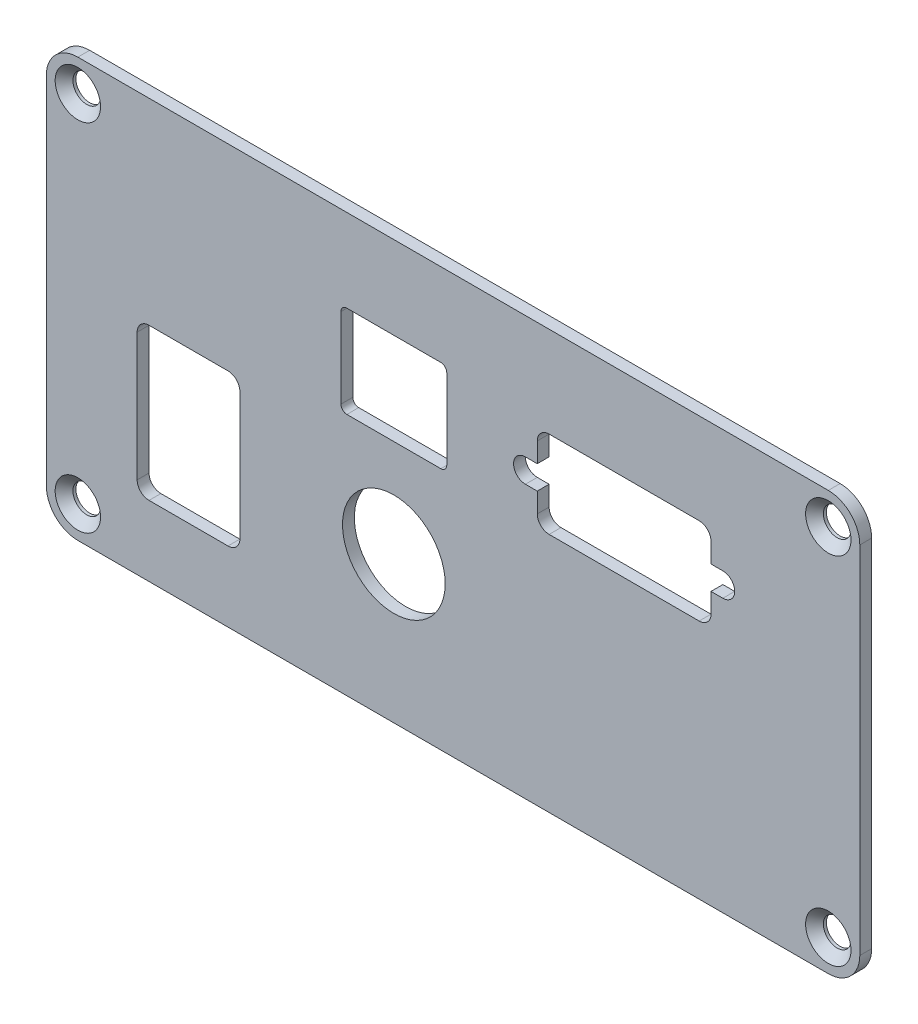
from build123d import *

# Parameters (mm, degrees)
ESQUISSE1_W                                 = 103
ESQUISSE1_H                                 = 53
BOSS_EXTRU_1_DEPTH                          = 1.5
FRAISAGE_POUR_VIS_T_TE_FRAIS_E_M31_AT_COUNT = 2
FRAISAGE_POUR_VIS_T_TE_FRAIS_E_M31_AT_PITCH = 95.02
FRAISAGE_POUR_VIS_T_TE_FRAIS_E_M31_2_COUNT  = 2
FRAISAGE_POUR_VIS_T_TE_FRAIS_E_M31_2_PITCH  = 105.137055314
FRAISAGE_POUR_VIS_T_TE_FRAIS_E_M31_3_COUNT  = 2
FRAISAGE_POUR_VIS_T_TE_FRAIS_E_M31_3_PITCH  = 45
CONG_1_R                                    = 3.99
ESQUISSE5_R                                 = 6.5
ENL_V_MAT_EXTRU_1_DEPTH                     = 2.5


with BuildPart() as part:
    # Esquisse1 → Boss.-Extru.1 (new body)
    with BuildSketch(Plane(origin=(0, 0, -0.75), x_dir=(-1, 0, 0), z_dir=(0, 0, -1))):
        Rectangle(ESQUISSE1_W, ESQUISSE1_H)
    extrude(amount=-BOSS_EXTRU_1_DEPTH)

    # Esquisse2 → Fraisage pour vis à tête fraisée M31 (revolve, cut)
    with BuildSketch(Plane(origin=(-47.51, 22.5, 0.75), x_dir=(0, -1, 0), z_dir=(1, 0, 0))):
        Polygon((0, 0), (0, 1.5), (1.75, 1.5), (1.75, 1.125), (2.875, 0), align=None)
    fraisage_pour_vis_t_te_frais_e_m31 = revolve(axis=Axis((-47.51, 22.5, 7.1), (0, 0, -1)), mode=Mode.SUBTRACT)

    # Fraisage pour vis à tête fraisée M31 at: Fraisage pour vis à tête fraisée M31 ×2
    with Locations(*[(i * FRAISAGE_POUR_VIS_T_TE_FRAIS_E_M31_AT_PITCH, 0, 0) for i in range(1, FRAISAGE_POUR_VIS_T_TE_FRAIS_E_M31_AT_COUNT)]):
        add(fraisage_pour_vis_t_te_frais_e_m31, mode=Mode.SUBTRACT)

    # Fraisage pour vis _ t_te frais_e M31 2: Fraisage pour vis à tête fraisée M31 ×2
    with Locations(*[Vector(0.903772697, -0.428012748, 0) * (i * FRAISAGE_POUR_VIS_T_TE_FRAIS_E_M31_2_PITCH) for i in range(1, FRAISAGE_POUR_VIS_T_TE_FRAIS_E_M31_2_COUNT)]):
        add(fraisage_pour_vis_t_te_frais_e_m31, mode=Mode.SUBTRACT)

    # Fraisage pour vis _ t_te frais_e M31 3: Fraisage pour vis à tête fraisée M31 ×2
    with Locations(*[(0, -i * FRAISAGE_POUR_VIS_T_TE_FRAIS_E_M31_3_PITCH, 0) for i in range(1, FRAISAGE_POUR_VIS_T_TE_FRAIS_E_M31_3_COUNT)]):
        add(fraisage_pour_vis_t_te_frais_e_m31, mode=Mode.SUBTRACT)

    # Congé1
    cong_1_edges = [part.edges().sort_by_distance(p)[0] for p in [
        (51.5, 26.5, 0),
        (-51.5, 26.5, 0),
        (-51.5, -26.5, 0),
        (51.5, -26.5, 0),
    ]]
    fillet(cong_1_edges, radius=CONG_1_R)

    # Esquisse5 → Enlèv. mat.-Extru.1 (cut, through all)
    with BuildSketch(Plane.XY.offset(0.75)):
        with Locations((-7.5, -8)):
            Circle(ESQUISSE5_R)
        with BuildLine():
            Line((-28.5, -17.6), (-38.5, -17.6))
            ThreePointArc((-38.5, -17.6), (-39.560660172, -17.160660172), (-40, -16.1))
            Line((-40, -16.1), (-40, 0.1))
            ThreePointArc((-40, 0.1), (-39.560660172, 1.160660172), (-38.5, 1.6))
            Line((-38.5, 1.6), (-28.5, 1.6))
            ThreePointArc((-28.5, 1.6), (-27.439339828, 1.160660172), (-27, 0.1))
            Line((-27, 0.1), (-27, -16.1))
            ThreePointArc((-27, -16.1), (-27.439339828, -17.160660172), (-28.5, -17.6))
        make_face()
        with BuildLine():
            Line((31.16, 4), (12.16, 4))
            ThreePointArc((12.16, 4), (11.099339828, 4.439339828), (10.66, 5.5))
            Line((10.66, 5.5), (10.66, 8))
            Line((10.66, 8), (9.16, 8))
            ThreePointArc((9.16, 8), (7.66, 9.5), (9.16, 11))
            Line((9.16, 11), (10.66, 11))
            Line((10.66, 11), (10.66, 13.5))
            ThreePointArc((10.66, 13.5), (11.099339828, 14.560660172), (12.16, 15))
            Line((12.16, 15), (31.16, 15))
            ThreePointArc((31.16, 15), (32.220660172, 14.560660172), (32.66, 13.5))
            Line((32.66, 13.5), (32.66, 11))
            Line((32.66, 11), (34.16, 11))
            ThreePointArc((34.16, 11), (35.66, 9.5), (34.16, 8))
            Line((34.16, 8), (32.66, 8))
            Line((32.66, 8), (32.66, 5.5))
            ThreePointArc((32.66, 5.5), (32.220660172, 4.439339828), (31.16, 4))
        make_face()
        with BuildLine():
            Line((-13.45, 4.35), (-1.55, 4.35))
            ThreePointArc((-1.55, 4.35), (-1.019669914, 4.569669914), (-0.8, 5.1))
            Line((-0.8, 5.1), (-0.8, 15.25))
            ThreePointArc((-0.8, 15.25), (-1.019669914, 15.780330086), (-1.55, 16))
            Line((-1.55, 16), (-13.45, 16))
            ThreePointArc((-13.45, 16), (-13.980330086, 15.780330086), (-14.2, 15.25))
            Line((-14.2, 15.25), (-14.2, 5.1))
            ThreePointArc((-14.2, 5.1), (-13.980330086, 4.569669914), (-13.45, 4.35))
        make_face()
    extrude(amount=-ENL_V_MAT_EXTRU_1_DEPTH, mode=Mode.SUBTRACT)


solid = part.part
